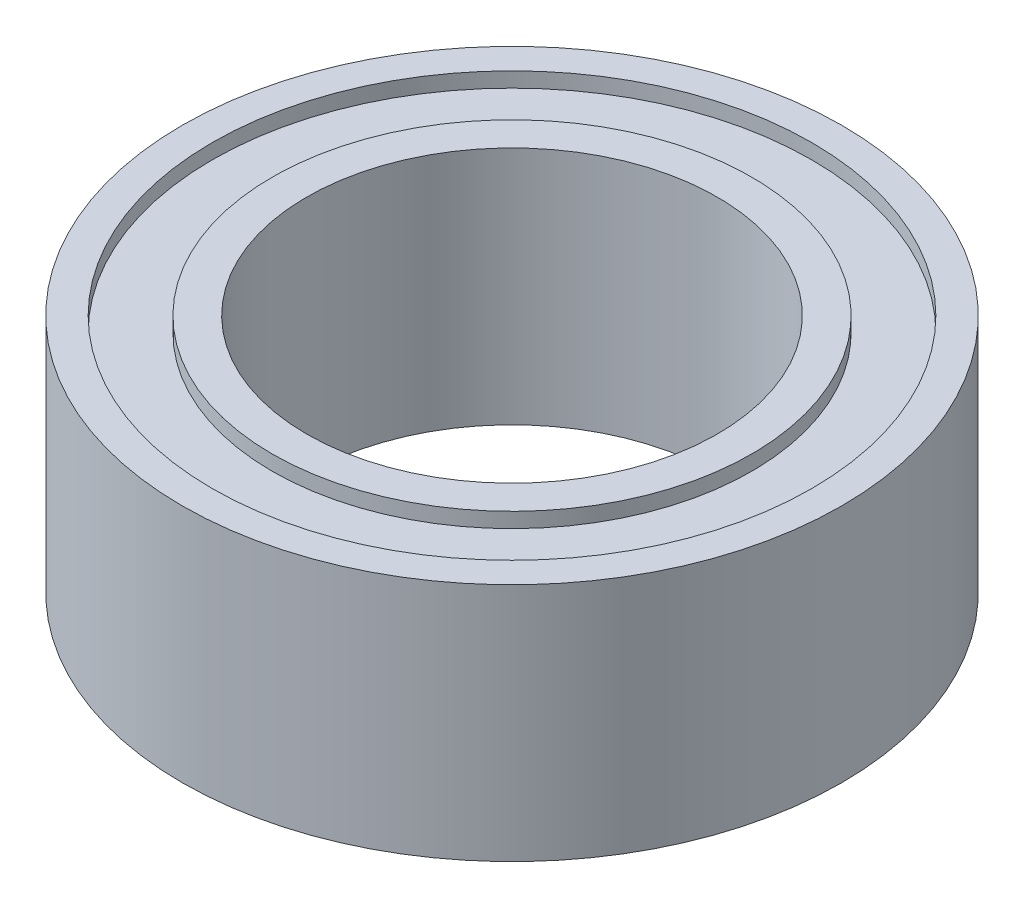
from build123d import *

# Parameters (mm, degrees)
SKETCH1_R           = 11
BOSS_EXTRUDE1_DEPTH = 4
SKETCH2_R           = 6.85
CUT_EXTRUDE1_DEPTH  = 11.96
SKETCH3_R           = 10
SKETCH3_R_2         = 8
CUT_EXTRUDE2_DEPTH  = 0.5


with BuildPart() as part:
    # Sketch1 → Boss-Extrude1 (new body, symmetric)
    with BuildSketch(Plane(origin=(0, 0, 0), x_dir=(1, 0, 0), z_dir=(0, 1, 0))):
        Circle(SKETCH1_R)
    extrude(amount=BOSS_EXTRUDE1_DEPTH, both=True)

    # Sketch2 → Cut-Extrude1 (cut)
    with BuildSketch(Plane(origin=(0, 4, 0), x_dir=(1, 0, 0), z_dir=(0, 1, 0))):
        Circle(SKETCH2_R)
    extrude(amount=-CUT_EXTRUDE1_DEPTH, mode=Mode.SUBTRACT)

    # Sketch3 → Cut-Extrude2 (cut)
    with BuildSketch(Plane(origin=(0, 4, 0), x_dir=(1, 0, 0), z_dir=(0, 1, 0))):
        Circle(SKETCH3_R)
        Circle(SKETCH3_R_2, mode=Mode.SUBTRACT)
    cut_extrude2 = extrude(amount=-CUT_EXTRUDE2_DEPTH, mode=Mode.SUBTRACT)

    # Mirror1: Cut-Extrude2 across plane
    add(cut_extrude2.mirror(Plane.ZX), mode=Mode.SUBTRACT)


solid = part.part
